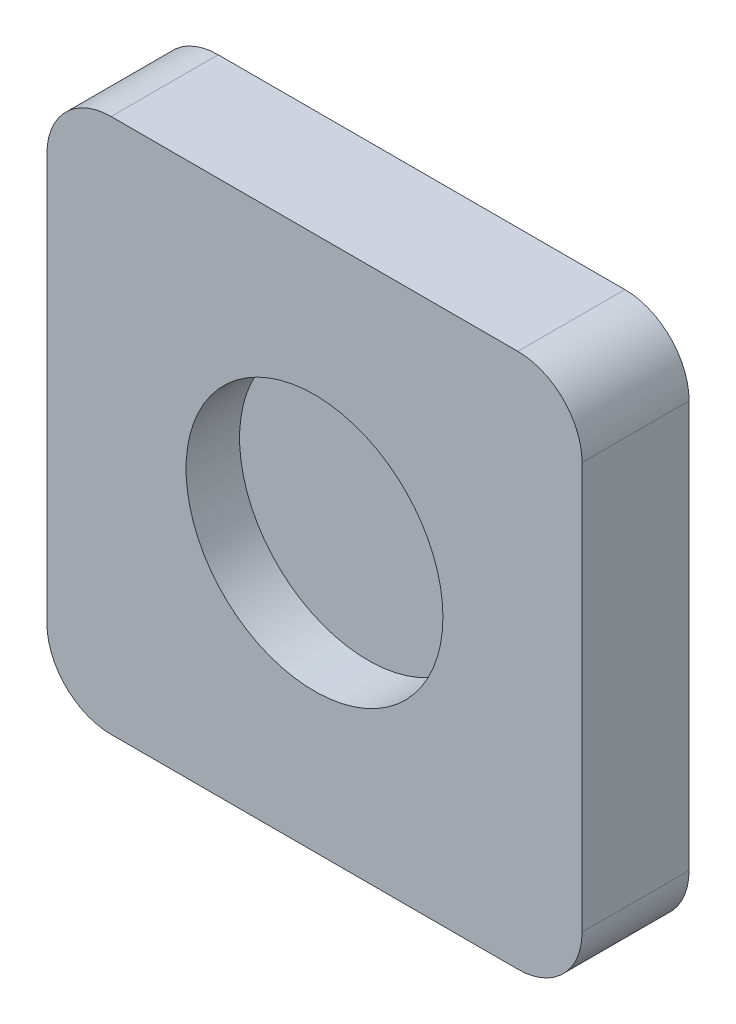
from build123d import *

# Parameters (mm, degrees)
BOSS_EXTRUDE1_DEPTH = 0.05
SKETCH2_R           = 0.06
CUT_EXTRUDE1_DEPTH  = 0.025


with BuildPart() as part:
    # Sketch1 → Boss-Extrude1 (new body)
    with BuildSketch(Plane.XY):
        with BuildLine():
            Line((-0.095, -0.125), (0.095, -0.125))
            ThreePointArc((0.095, -0.125), (0.116213203, -0.116213203), (0.125, -0.095))
            Line((0.125, -0.095), (0.125, 0.095))
            ThreePointArc((0.125, 0.095), (0.116213203, 0.116213203), (0.095, 0.125))
            Line((0.095, 0.125), (-0.095, 0.125))
            ThreePointArc((-0.095, 0.125), (-0.116213203, 0.116213203), (-0.125, 0.095))
            Line((-0.125, 0.095), (-0.125, -0.095))
            ThreePointArc((-0.125, -0.095), (-0.116213203, -0.116213203), (-0.095, -0.125))
        make_face()
    extrude(amount=BOSS_EXTRUDE1_DEPTH)

    # Sketch2 → Cut-Extrude1 (cut)
    with BuildSketch(Plane.XY.offset(0.05)):
        Circle(SKETCH2_R)
    extrude(amount=-CUT_EXTRUDE1_DEPTH, mode=Mode.SUBTRACT)


solid = part.part
